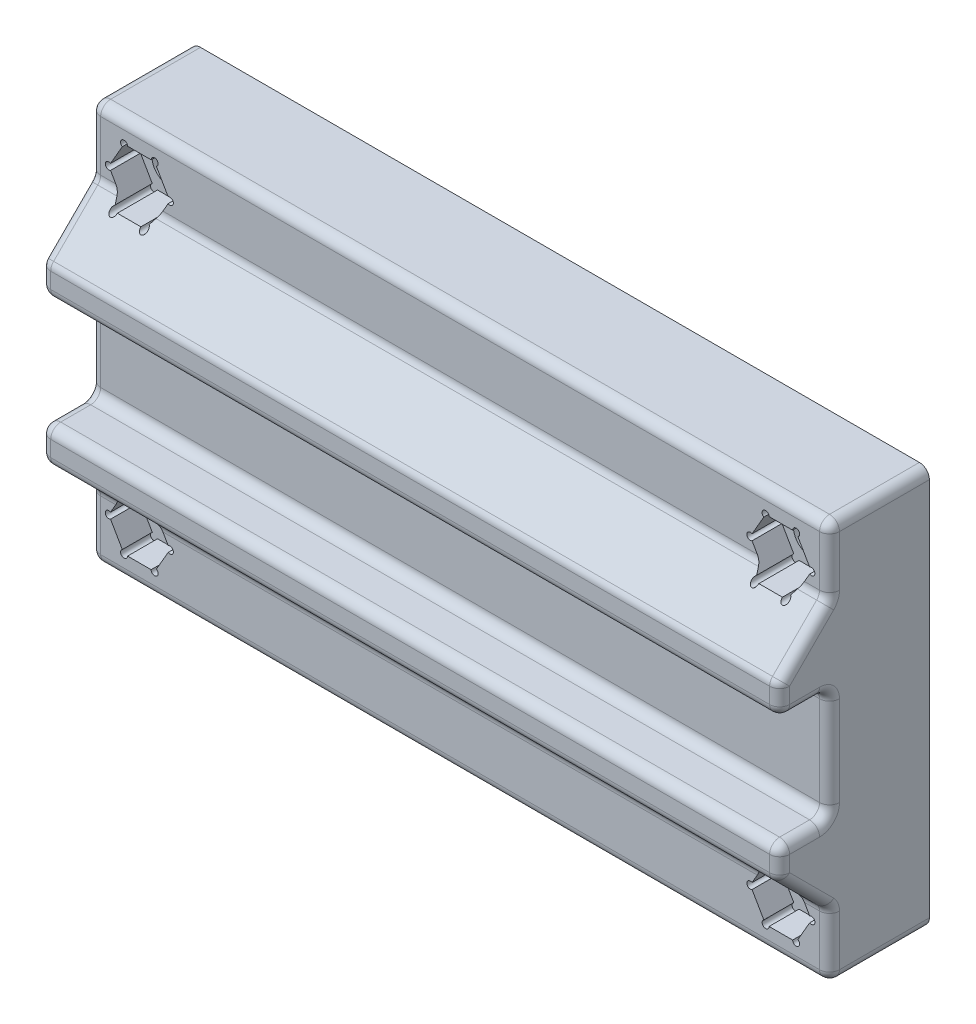
from build123d import *

# Parameters (mm, degrees)
SKETCH1_W               = 74
SKETCH1_H               = 40
BOSS_EXTRUDE1_DEPTH     = 10
BOSS_EXTRUDE2_DEPTH     = 74
SKETCH3_R               = 1.75
CUT_EXTRUDE1_DEPTH      = 6
CUT_EXTRUDE1_DEPTH_BACK = 11
CUT_EXTRUDE2_DEPTH      = 6
CUT_EXTRUDE2_DEPTH_BACK = 3
FILLET1_R               = 1


with BuildPart() as part:
    # Sketch1 → Boss-Extrude1 (new body)
    with BuildSketch(Plane.XY):
        Rectangle(SKETCH1_W, SKETCH1_H)
    extrude(amount=BOSS_EXTRUDE1_DEPTH)

    # Sketch2 → Boss-Extrude2 (add)
    with BuildSketch(Plane.ZY.offset(37)):
        Polygon((10, 13.5), (10, 5.5), (15, 5.5), (15, 8.5), align=None)
        Polygon((15, -5.5), (10, -5.5), (10, -13.5), (15, -8.5), align=None)
    extrude(amount=-BOSS_EXTRUDE2_DEPTH)

    # Sketch3 → Cut-Extrude1 (cut, two sides)
    with BuildSketch(Plane.XY.offset(10)) as cut_extrude1_sk:
        with Locations((32.125, 15.125)):
            Circle(SKETCH3_R)
        with Locations((32.125, -15.125)):
            Circle(SKETCH3_R)
        with Locations((-32.125, -15.125)):
            Circle(SKETCH3_R)
        with Locations((-32.125, 15.125)):
            Circle(SKETCH3_R)
    extrude(amount=CUT_EXTRUDE1_DEPTH, mode=Mode.SUBTRACT)
    extrude(cut_extrude1_sk.sketch, amount=-CUT_EXTRUDE1_DEPTH_BACK, mode=Mode.SUBTRACT)

    # Sketch4 → Cut-Extrude2 (cut, two sides)
    with BuildSketch(Plane.XY.offset(10)) as cut_extrude2_sk:
        with BuildLine():
            Line((35.009956427, 15.428108891), (33.829978213, 17.471891109))
            ThreePointArc((33.829978213, 17.471891109), (33.829978213, 18.078108891), (33.304978213, 17.775))
            Line((33.304978213, 17.775), (30.945021787, 17.775))
            ThreePointArc((30.945021787, 17.775), (30.420021787, 18.078108891), (30.420021787, 17.471891109))
            Line((30.420021787, 17.471891109), (29.240043573, 15.428108891))
            ThreePointArc((29.240043573, 15.428108891), (28.715043573, 15.125), (29.240043573, 14.821891109))
            Line((29.240043573, 14.821891109), (30.420021787, 12.778108891))
            ThreePointArc((30.420021787, 12.778108891), (30.420021787, 12.171891109), (30.945021787, 12.475))
            Line((30.945021787, 12.475), (33.304978213, 12.475))
            ThreePointArc((33.304978213, 12.475), (33.829978213, 12.171891109), (33.829978213, 12.778108891))
            Line((33.829978213, 12.778108891), (35.009956427, 14.821891109))
            ThreePointArc((35.009956427, 14.821891109), (35.534956427, 15.125), (35.009956427, 15.428108891))
        make_face()
        with BuildLine():
            Line((-29.240043573, 15.428108891), (-30.420021787, 17.471891109))
            ThreePointArc((-30.420021787, 17.471891109), (-30.420021787, 18.078108891), (-30.945021787, 17.775))
            Line((-30.945021787, 17.775), (-33.304978213, 17.775))
            ThreePointArc((-33.304978213, 17.775), (-33.829978213, 18.078108891), (-33.829978213, 17.471891109))
            Line((-33.829978213, 17.471891109), (-35.009956427, 15.428108891))
            ThreePointArc((-35.009956427, 15.428108891), (-35.534956427, 15.125), (-35.009956427, 14.821891109))
            Line((-35.009956427, 14.821891109), (-33.829978213, 12.778108891))
            ThreePointArc((-33.829978213, 12.778108891), (-33.829978213, 12.171891109), (-33.304978213, 12.475))
            Line((-33.304978213, 12.475), (-30.945021787, 12.475))
            ThreePointArc((-30.945021787, 12.475), (-30.420021787, 12.171891109), (-30.420021787, 12.778108891))
            Line((-30.420021787, 12.778108891), (-29.240043573, 14.821891109))
            ThreePointArc((-29.240043573, 14.821891109), (-28.715043573, 15.125), (-29.240043573, 15.428108891))
        make_face()
        with BuildLine():
            Line((-29.240043573, -14.821891109), (-30.420021787, -12.778108891))
            ThreePointArc((-30.420021787, -12.778108891), (-30.420021787, -12.171891109), (-30.945021787, -12.475))
            Line((-30.945021787, -12.475), (-33.304978213, -12.475))
            ThreePointArc((-33.304978213, -12.475), (-33.829978213, -12.171891109), (-33.829978213, -12.778108891))
            Line((-33.829978213, -12.778108891), (-35.009956427, -14.821891109))
            ThreePointArc((-35.009956427, -14.821891109), (-35.534956427, -15.125), (-35.009956427, -15.428108891))
            Line((-35.009956427, -15.428108891), (-33.829978213, -17.471891109))
            ThreePointArc((-33.829978213, -17.471891109), (-33.829978213, -18.078108891), (-33.304978213, -17.775))
            Line((-33.304978213, -17.775), (-30.945021787, -17.775))
            ThreePointArc((-30.945021787, -17.775), (-30.420021787, -18.078108891), (-30.420021787, -17.471891109))
            Line((-30.420021787, -17.471891109), (-29.240043573, -15.428108891))
            ThreePointArc((-29.240043573, -15.428108891), (-28.715043573, -15.125), (-29.240043573, -14.821891109))
        make_face()
        with BuildLine():
            Line((35.009956427, -14.821891109), (33.829978213, -12.778108891))
            ThreePointArc((33.829978213, -12.778108891), (33.829978213, -12.171891109), (33.304978213, -12.475))
            Line((33.304978213, -12.475), (30.945021787, -12.475))
            ThreePointArc((30.945021787, -12.475), (30.420021787, -12.171891109), (30.420021787, -12.778108891))
            Line((30.420021787, -12.778108891), (29.240043573, -14.821891109))
            ThreePointArc((29.240043573, -14.821891109), (28.715043573, -15.125), (29.240043573, -15.428108891))
            Line((29.240043573, -15.428108891), (30.420021787, -17.471891109))
            ThreePointArc((30.420021787, -17.471891109), (30.420021787, -18.078108891), (30.945021787, -17.775))
            Line((30.945021787, -17.775), (33.304978213, -17.775))
            ThreePointArc((33.304978213, -17.775), (33.829978213, -18.078108891), (33.829978213, -17.471891109))
            Line((33.829978213, -17.471891109), (35.009956427, -15.428108891))
            ThreePointArc((35.009956427, -15.428108891), (35.534956427, -15.125), (35.009956427, -14.821891109))
        make_face()
    extrude(amount=CUT_EXTRUDE2_DEPTH, mode=Mode.SUBTRACT)
    extrude(cut_extrude2_sk.sketch, amount=-CUT_EXTRUDE2_DEPTH_BACK, mode=Mode.SUBTRACT)

    # Fillet1
    fillet1_edges = [part.edges().sort_by_distance(p)[0] for p in [
        (-37, 16.75, 10),
        (37, 16.75, 10),
        (-37, 0, 10),
        (0, 8.5, 15),
        (0, 5.5, 15),
        (0, 5.5, 10),
        (0, -20, 10),
        (35.62338112, 13.5, 10),
        (-37, 7, 15),
        (-37, 11, 12.5),
        (-37, 5.5, 12.5),
        (37, 7, 15),
        (37, 5.5, 12.5),
        (37, 11, 12.5),
        (37, 0, 10),
        (-37, -16.75, 10),
        (35.62338112, -13.5, 10),
        (37, -11, 12.5),
        (0, -8.5, 15),
        (-37, -11, 12.5),
        (37, -7, 15),
        (0, -5.5, 15),
        (-37, -7, 15),
        (37, -5.5, 12.5),
        (0, -5.5, 10),
        (-37, -5.5, 12.5),
        (37, -16.75, 10),
        (-35.62338112, -13.5, 10),
        (0, -13.5, 10),
        (-35.62338112, 13.5, 10),
        (0, 13.5, 10),
        (37, -20, 5),
        (-37, -20, 5),
        (-37, 20, 5),
        (37, 20, 5),
        (0, 20, 10),
    ]]
    fillet(fillet1_edges, radius=FILLET1_R)


solid = part.part
